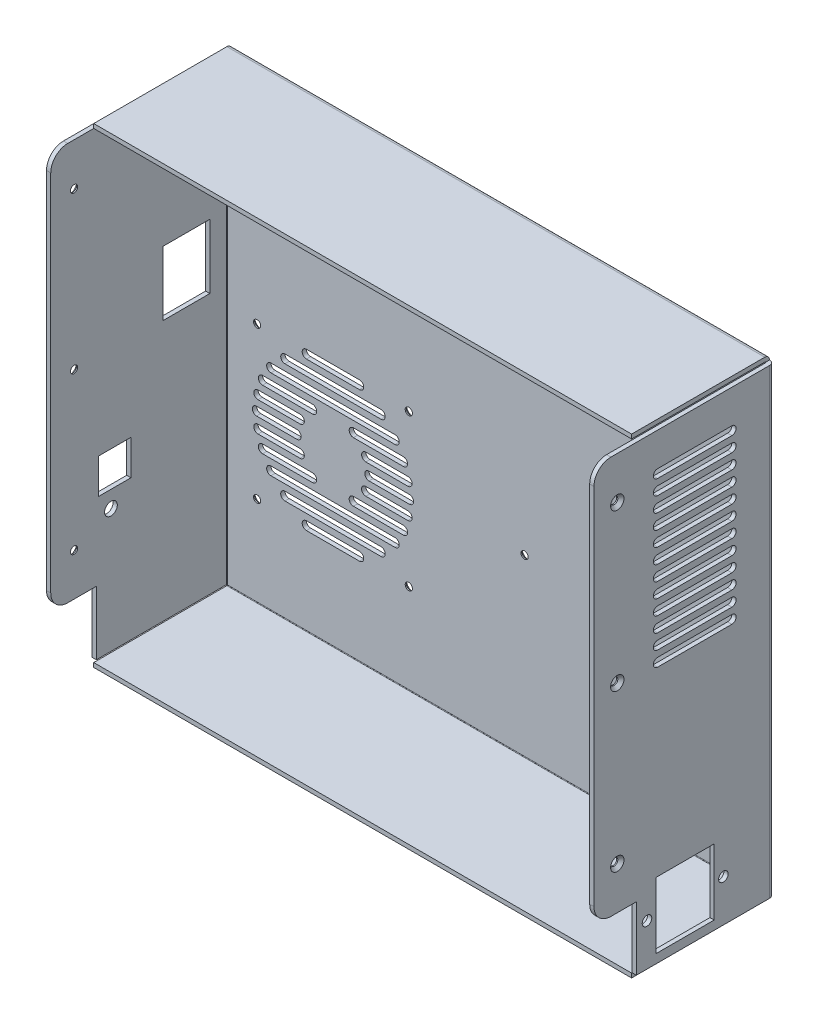
from build123d import *

# Parameters (mm, degrees)
SKETCH1_W                                       = 258
SKETCH1_H                                       = 222
BOSS_EXTRUDE1_DEPTH                             = 2
SKETCH2_W                                       = 258
SKETCH2_H                                       = 222
SKETCH2_W_2                                     = 254
SKETCH2_H_2                                     = 218
BOSS_EXTRUDE2_DEPTH                             = 63
FILLET1_R                                       = 0.25
FILLET2_R                                       = 2.25
SKETCH3_W                                       = 2.25
SKETCH3_H                                       = 2.25
CUT_EXTRUDE1_DEPTH                              = 66
SKETCH4_W                                       = 2
SKETCH4_H                                       = 187.5
BOSS_EXTRUDE3_DEPTH                             = 20
SKETCH6_R                                       = 2.25
SKETCH6_R_2                                     = 1.5
SKETCH6_W                                       = 27.3
SKETCH6_H                                       = 31.1
CUT_EXTRUDE3_DEPTH                              = 15
SKETCH5_R                                       = 1.5
SKETCH5_R_2                                     = 3
SKETCH5_W                                       = 22
SKETCH5_H                                       = 30.3
SKETCH5_W_2                                     = 15.2
SKETCH5_H_2                                     = 16.5
CUT_EXTRUDE2_DEPTH                              = 15
FILLET3_R                                       = 8
SKETCH8_R                                       = 1.5
SKETCH8_R_2                                     = 1.75
CUT_EXTRUDE5_DEPTH                              = 15
SKETCH10_W                                      = 2
SKETCH10_H                                      = 30
CUT_EXTRUDE7_DEPTH                              = 1.5
CSK_FOR_M3_FLAT_HEAD_MACHINE_SCREW1_D           = 3.4
CSK_FOR_M3_FLAT_HEAD_MACHINE_SCREW1_DEPTH       = 10
CSK_FOR_M3_FLAT_HEAD_MACHINE_SCREW1_CSINK_D     = 6.3
CSK_FOR_M3_FLAT_HEAD_MACHINE_SCREW1_CSINK_ANGLE = 90
CSK_FOR_M3_FLAT_HEAD_MACHINE_SCREW1_TIP         = 1.021463052
CSK_FOR_M3_FLAT_HEAD_MACHINE_SCREW2_D           = 3.4
CSK_FOR_M3_FLAT_HEAD_MACHINE_SCREW2_DEPTH       = 10
CSK_FOR_M3_FLAT_HEAD_MACHINE_SCREW2_CSINK_D     = 6.3
CSK_FOR_M3_FLAT_HEAD_MACHINE_SCREW2_CSINK_ANGLE = 90
CSK_FOR_M3_FLAT_HEAD_MACHINE_SCREW2_TIP         = 1.021463052
CSK_FOR_M3_FLAT_HEAD_MACHINE_SCREW3_D           = 3.4
CSK_FOR_M3_FLAT_HEAD_MACHINE_SCREW3_DEPTH       = 10
CSK_FOR_M3_FLAT_HEAD_MACHINE_SCREW3_CSINK_D     = 6.3
CSK_FOR_M3_FLAT_HEAD_MACHINE_SCREW3_CSINK_ANGLE = 90
CSK_FOR_M3_FLAT_HEAD_MACHINE_SCREW3_TIP         = 1.021463052
CUT_EXTRUDE8_DEPTH                              = 10
LPATTERN1_COUNT                                 = 12
LPATTERN1_PITCH                                 = 7


with BuildPart() as part:
    # Sketch1 → Boss-Extrude1 (new body)
    with BuildSketch(Plane.XY):
        Rectangle(SKETCH1_W, SKETCH1_H)
    extrude(amount=BOSS_EXTRUDE1_DEPTH)

    # Sketch2 → Boss-Extrude2 (add)
    with BuildSketch(Plane.XY.offset(2)):
        Rectangle(SKETCH2_W, SKETCH2_H)
        Rectangle(SKETCH2_W_2, SKETCH2_H_2, mode=Mode.SUBTRACT)
    extrude(amount=BOSS_EXTRUDE2_DEPTH)

    # Fillet1
    fillet1_edges = [part.edges().sort_by_distance(p)[0] for p in [
        (-127, 0, 2),
        (0, -109, 2),
        (127, 0, 2),
        (0, 109, 2),
    ]]
    fillet(fillet1_edges, radius=FILLET1_R)

    # Fillet2
    fillet2_edges = [part.edges().sort_by_distance(p)[0] for p in [
        (0, 111, 0),
        (129, 0, 0),
        (0, -111, 0),
        (-129, 0, 0),
    ]]
    fillet(fillet2_edges, radius=FILLET2_R)

    # Sketch3 → Cut-Extrude1 (cut, through all)
    with BuildSketch(Plane.XY.offset(65)):
        with Locations((-127.875, 109.875)):
            Rectangle(SKETCH3_W, SKETCH3_H)
        with Locations((127.875, 109.875)):
            Rectangle(SKETCH3_W, SKETCH3_H)
        with Locations((127.875, -109.875)):
            Rectangle(SKETCH3_W, SKETCH3_H)
        with Locations((-127.875, -109.875)):
            Rectangle(SKETCH3_W, SKETCH3_H)
    extrude(amount=-CUT_EXTRUDE1_DEPTH, mode=Mode.SUBTRACT)

    # Sketch4 → Boss-Extrude3 (add)
    with BuildSketch(Plane.XY.offset(65)):
        with Locations((-128, 15)):
            Rectangle(SKETCH4_W, SKETCH4_H)
        with Locations((128, 15)):
            Rectangle(SKETCH4_W, SKETCH4_H)
    extrude(amount=BOSS_EXTRUDE3_DEPTH)

    # Sketch6 → Cut-Extrude3 (cut)
    with BuildSketch(Plane(origin=(129, 0, 0), x_dir=(0, 0, -1), z_dir=(1, 0, 0))):
        with Locations(Location((-24, -89, 0), (0, 0, 90))):  # turned: the seam where the file's is
            Circle(SKETCH6_R)
        with Locations(Location((-60, -89, 0), (0, 0, 90))):  # turned: the seam where the file's is
            Circle(SKETCH6_R)
        with Locations(Location((-74, -58.75, 0), (0, 0, 90))):  # turned: the seam where the file's is
            Circle(SKETCH6_R_2)
        with Locations(Location((-74, 15, 0), (0, 0, 90))):  # turned: the seam where the file's is
            Circle(SKETCH6_R_2)
        with Locations(Location((-74, 88.75, 0), (0, 0, 90))):  # turned: the seam where the file's is
            Circle(SKETCH6_R_2)
        with Locations((-42, -89)):
            Rectangle(SKETCH6_W, SKETCH6_H)
    extrude(amount=-CUT_EXTRUDE3_DEPTH, mode=Mode.SUBTRACT)

    # Sketch5 → Cut-Extrude2 (cut)
    with BuildSketch(Plane.ZY.offset(129)):
        with Locations(Location((74, 88.75, 0), (0, 0, 90))):  # turned: the seam where the file's is
            Circle(SKETCH5_R)
        with Locations(Location((74, 15, 0), (0, 0, 90))):  # turned: the seam where the file's is
            Circle(SKETCH5_R)
        with Locations(Location((74, -58.75, 0), (0, 0, 90))):  # turned: the seam where the file's is
            Circle(SKETCH5_R)
        with Locations(Location((56.62, -50.5, 0), (0, 0, 270))):  # turned: the seam where the file's is
            Circle(SKETCH5_R_2)
        with Locations((21, 29.15)):
            Rectangle(SKETCH5_W, SKETCH5_H)
        with Locations((54.82, -34.35)):
            Rectangle(SKETCH5_W_2, SKETCH5_H_2)
    extrude(amount=-CUT_EXTRUDE2_DEPTH, mode=Mode.SUBTRACT)

    # Fillet3
    fillet3_edges = [part.edges().sort_by_distance(p)[0] for p in [
        (128, -78.75, 85),
        (128, 108.75, 85),
        (-128, -78.75, 85),
        (-128, 108.75, 85),
    ]]
    fillet(fillet3_edges, radius=FILLET3_R)

    # Sketch8 → Cut-Extrude5 (cut)
    with BuildSketch(Plane(origin=(0, 0, 0), x_dir=(-1, 0, 0), z_dir=(0, 0, -1))):
        with Locations((41.25, 4.75)):
            Circle(SKETCH8_R)
        with Locations((41.25, -66.75)):
            Circle(SKETCH8_R)
        with Locations((112.75, 4.75)):
            Circle(SKETCH8_R)
        with Locations((112.75, -66.75)):
            Circle(SKETCH8_R)
        with Locations((-13.3, -26.6)):
            Circle(SKETCH8_R)
        with Locations((-93.3, -26.6)):
            Circle(SKETCH8_R)
        with Locations((-93.3, 93.4)):
            Circle(SKETCH8_R)
        with Locations((-13.3, 93.4)):
            Circle(SKETCH8_R)
        with Locations((-67, -96)):
            Circle(SKETCH8_R_2)
        with BuildLine():
            Line((41, -29), (60, -29))
            ThreePointArc((60, -29), (62, -31), (60, -33))
            Line((60, -33), (41, -33))
            ThreePointArc((41, -33), (39, -31), (41, -29))
        make_face()
        with BuildLine():
            Line((47.759616966, -8), (106.240383034, -8))
            ThreePointArc((106.240383034, -8), (108.240383034, -10), (106.240383034, -12))
            Line((106.240383034, -12), (47.759616966, -12))
            ThreePointArc((47.759616966, -12), (45.759616966, -10), (47.759616966, -8))
        make_face()
        with BuildLine():
            Line((43.833752096, -15), (67.356349239, -15))
            ThreePointArc((67.356349239, -15), (69.356349239, -17), (67.356349239, -19))
            Line((67.356349239, -19), (43.833752096, -19))
            ThreePointArc((43.833752096, -19), (41.833752096, -17), (43.833752096, -15))
        make_face()
        with BuildLine():
            Line((41.687112834, -22), (61.508066615, -22))
            ThreePointArc((61.508066615, -22), (63.508066615, -24), (61.508066615, -26))
            Line((61.508066615, -26), (41.687112834, -26))
            ThreePointArc((41.687112834, -26), (39.687112834, -24), (41.687112834, -22))
        make_face()
        with BuildLine():
            Line((54.372583002, -1), (99.627416998, -1))
            ThreePointArc((99.627416998, -1), (101.627416998, -3), (99.627416998, -5))
            Line((99.627416998, -5), (54.372583002, -5))
            ThreePointArc((54.372583002, -5), (52.372583002, -3), (54.372583002, -1))
        make_face()
        with BuildLine():
            Line((64.5, 6), (89.5, 6))
            ThreePointArc((89.5, 6), (91.5, 4), (89.5, 2))
            Line((89.5, 2), (64.5, 2))
            ThreePointArc((64.5, 2), (62.5, 4), (64.5, 6))
        make_face()
        with BuildLine():
            Line((86.643650761, -15), (110.166247904, -15))
            ThreePointArc((110.166247904, -15), (112.166247904, -17), (110.166247904, -19))
            Line((110.166247904, -19), (86.643650761, -19))
            ThreePointArc((86.643650761, -19), (84.643650761, -17), (86.643650761, -15))
        make_face()
        with BuildLine():
            Line((92.491933385, -22), (112.312887166, -22))
            ThreePointArc((112.312887166, -22), (114.312887166, -24), (112.312887166, -26))
            Line((112.312887166, -26), (92.491933385, -26))
            ThreePointArc((92.491933385, -26), (90.491933385, -24), (92.491933385, -22))
        make_face()
        with BuildLine():
            Line((94, -29), (113, -29))
            ThreePointArc((113, -29), (115, -31), (113, -33))
            Line((113, -33), (94, -33))
            ThreePointArc((94, -33), (92, -31), (94, -29))
        make_face()
        with BuildLine():
            Line((92.491933385, -36), (112.312887166, -36))
            ThreePointArc((112.312887166, -36), (114.312887166, -38), (112.312887166, -40))
            Line((112.312887166, -40), (92.491933385, -40))
            ThreePointArc((92.491933385, -40), (90.491933385, -38), (92.491933385, -36))
        make_face()
        with BuildLine():
            Line((86.643650761, -43), (110.166247904, -43))
            ThreePointArc((110.166247904, -43), (112.166247904, -45), (110.166247904, -47))
            Line((110.166247904, -47), (86.643650761, -47))
            ThreePointArc((86.643650761, -47), (84.643650761, -45), (86.643650761, -43))
        make_face()
        with BuildLine():
            Line((41.687112834, -36), (61.508066615, -36))
            ThreePointArc((61.508066615, -36), (63.508066615, -38), (61.508066615, -40))
            Line((61.508066615, -40), (41.687112834, -40))
            ThreePointArc((41.687112834, -40), (39.687112834, -38), (41.687112834, -36))
        make_face()
        with BuildLine():
            Line((43.833752096, -43), (67.356349239, -43))
            ThreePointArc((67.356349239, -43), (69.356349239, -45), (67.356349239, -47))
            Line((67.356349239, -47), (43.833752096, -47))
            ThreePointArc((43.833752096, -47), (41.833752096, -45), (43.833752096, -43))
        make_face()
        with BuildLine():
            Line((47.759616966, -50), (106.240383034, -50))
            ThreePointArc((106.240383034, -50), (108.240383034, -52), (106.240383034, -54))
            Line((106.240383034, -54), (47.759616966, -54))
            ThreePointArc((47.759616966, -54), (45.759616966, -52), (47.759616966, -50))
        make_face()
        with BuildLine():
            Line((54.372583002, -57), (99.627416998, -57))
            ThreePointArc((99.627416998, -57), (101.627416998, -59), (99.627416998, -61))
            Line((99.627416998, -61), (54.372583002, -61))
            ThreePointArc((54.372583002, -61), (52.372583002, -59), (54.372583002, -57))
        make_face()
        with BuildLine():
            Line((64.5, -64), (89.5, -64))
            ThreePointArc((89.5, -64), (91.5, -66), (89.5, -68))
            Line((89.5, -68), (64.5, -68))
            ThreePointArc((64.5, -68), (62.5, -66), (64.5, -64))
        make_face()
    extrude(amount=-CUT_EXTRUDE5_DEPTH, mode=Mode.SUBTRACT)

    # Sketch10 → Cut-Extrude7 (cut)
    with BuildSketch(Plane.XY.offset(65)):
        with Locations((-128, -93.75)):
            Rectangle(SKETCH10_W, SKETCH10_H)
    extrude(amount=-CUT_EXTRUDE7_DEPTH, mode=Mode.SUBTRACT)

    # CSK for M3 Flat Head Machine Screw1
    with Locations(Plane(origin=(129, 0, 0), x_dir=(0, 0, -1), z_dir=(1, 0, 0))):
        with Locations((-74, 88.75), (-74, 15), (-74, -58.75)):
            CounterSinkHole(CSK_FOR_M3_FLAT_HEAD_MACHINE_SCREW1_D / 2, CSK_FOR_M3_FLAT_HEAD_MACHINE_SCREW1_CSINK_D / 2, depth=CSK_FOR_M3_FLAT_HEAD_MACHINE_SCREW1_DEPTH, counter_sink_angle=CSK_FOR_M3_FLAT_HEAD_MACHINE_SCREW1_CSINK_ANGLE)
            with Locations((0, 0, -(CSK_FOR_M3_FLAT_HEAD_MACHINE_SCREW1_DEPTH + CSK_FOR_M3_FLAT_HEAD_MACHINE_SCREW1_TIP / 2))):  # 118° drill point
                Cone(0, CSK_FOR_M3_FLAT_HEAD_MACHINE_SCREW1_D / 2, CSK_FOR_M3_FLAT_HEAD_MACHINE_SCREW1_TIP, mode=Mode.SUBTRACT)

    # CSK for M3 Flat Head Machine Screw2
    with Locations(Plane.ZY.offset(129)):
        with Locations((74, 88.75), (74, 15), (74, -58.75)):
            CounterSinkHole(CSK_FOR_M3_FLAT_HEAD_MACHINE_SCREW2_D / 2, CSK_FOR_M3_FLAT_HEAD_MACHINE_SCREW2_CSINK_D / 2, depth=CSK_FOR_M3_FLAT_HEAD_MACHINE_SCREW2_DEPTH, counter_sink_angle=CSK_FOR_M3_FLAT_HEAD_MACHINE_SCREW2_CSINK_ANGLE)
            with Locations((0, 0, -(CSK_FOR_M3_FLAT_HEAD_MACHINE_SCREW2_DEPTH + CSK_FOR_M3_FLAT_HEAD_MACHINE_SCREW2_TIP / 2))):  # 118° drill point
                Cone(0, CSK_FOR_M3_FLAT_HEAD_MACHINE_SCREW2_D / 2, CSK_FOR_M3_FLAT_HEAD_MACHINE_SCREW2_TIP, mode=Mode.SUBTRACT)

    # CSK for M3 Flat Head Machine Screw3
    with Locations(Plane(origin=(0, 0, 0), x_dir=(-1, 0, 0), z_dir=(0, 0, -1))):
        with Locations((41.25, 4.75), (112.75, 4.75), (112.75, -66.75), (41.25, -66.75), (-93.3, 93.4), (-13.3, 93.4), (-13.3, -26.6), (-93.3, -26.6)):
            CounterSinkHole(CSK_FOR_M3_FLAT_HEAD_MACHINE_SCREW3_D / 2, CSK_FOR_M3_FLAT_HEAD_MACHINE_SCREW3_CSINK_D / 2, depth=CSK_FOR_M3_FLAT_HEAD_MACHINE_SCREW3_DEPTH, counter_sink_angle=CSK_FOR_M3_FLAT_HEAD_MACHINE_SCREW3_CSINK_ANGLE)
            with Locations((0, 0, -(CSK_FOR_M3_FLAT_HEAD_MACHINE_SCREW3_DEPTH + CSK_FOR_M3_FLAT_HEAD_MACHINE_SCREW3_TIP / 2))):  # 118° drill point
                Cone(0, CSK_FOR_M3_FLAT_HEAD_MACHINE_SCREW3_D / 2, CSK_FOR_M3_FLAT_HEAD_MACHINE_SCREW3_TIP, mode=Mode.SUBTRACT)

    # Sketch17 → Cut-Extrude8 (cut)
    with BuildSketch(Plane(origin=(129, 0, 0), x_dir=(0, 0, -1), z_dir=(1, 0, 0))):
        with BuildLine():
            Line((-55, 93), (-20, 93))
            ThreePointArc((-20, 93), (-18, 91), (-20, 89))
            Line((-20, 89), (-55, 89))
            ThreePointArc((-55, 89), (-57, 91), (-55, 93))
        make_face()
    cut_extrude8 = extrude(amount=-CUT_EXTRUDE8_DEPTH, mode=Mode.SUBTRACT)

    # LPattern1: Cut-Extrude8 ×12
    with Locations(*[(0, -i * LPATTERN1_PITCH, 0) for i in range(1, LPATTERN1_COUNT)]):
        add(cut_extrude8, mode=Mode.SUBTRACT)


solid = part.part
